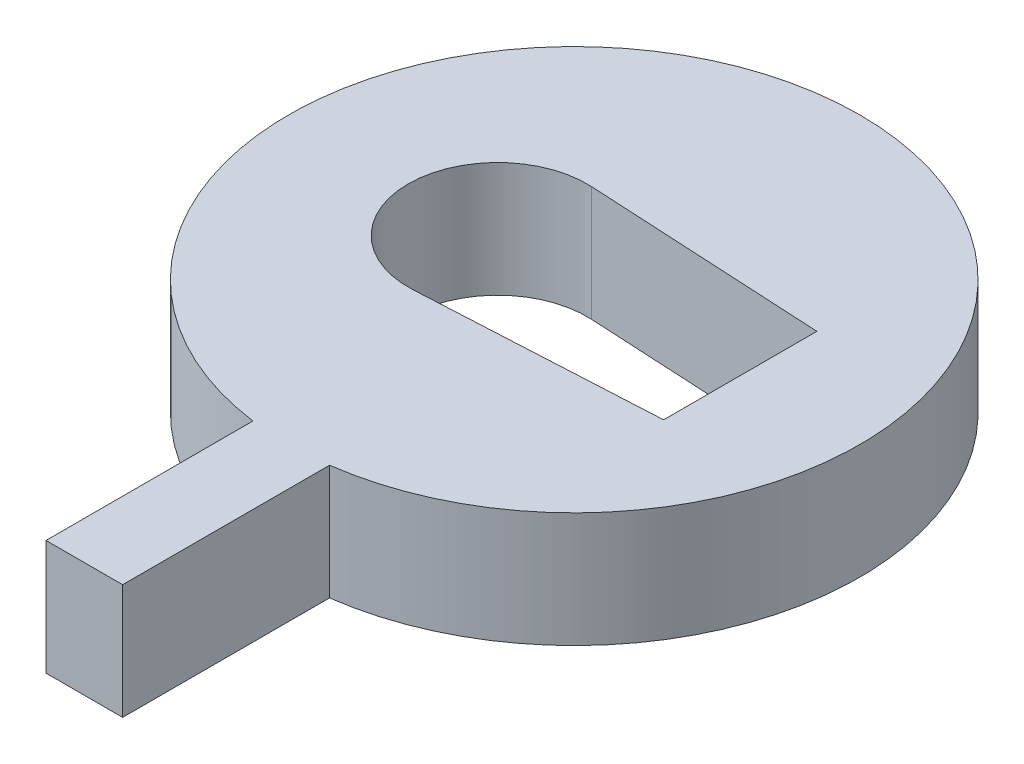
from build123d import *

# Parameters (mm, degrees)
SKETCH_1_W          = 20
SKETCH_1_H          = 10
EXTRUDE_1_DEPTH     = 4.5
CUT_EXTRUDE_1_DEPTH = 4.5
EXTRUDE_2_DEPTH     = 4.5
SKETCH_5_W          = 3
SKETCH_5_H          = 3
CUT_EXTRUDE_2_DEPTH = 4.5
SKETCH_6_W          = 3
SKETCH_6_H          = 4.5
EXTRUDE_3_DEPTH     = 11


with BuildPart() as part:
    # 草图1 → 凸台-拉伸1 (new body)
    with BuildSketch(Plane(origin=(0, 0, 0), x_dir=(1, 0, 0), z_dir=(0, 1, 0))):
        Rectangle(SKETCH_1_W, SKETCH_1_H)
    extrude(amount=EXTRUDE_1_DEPTH)

    # 草图2 → 切除-拉伸1 (cut)
    with BuildSketch(Plane(origin=(0, 4.5, 0), x_dir=(1, 0, 0), z_dir=(0, 1, 0))):
        with BuildLine():
            Line((-2.814231537, 3.495066534), (6.5, 3))
            Line((6.5, 3), (6.5, -3))
            Line((6.5, -3), (-2.814231537, -3.495066534))
            ThreePointArc((-2.814231537, -3.495066534), (-6.5, 0), (-2.814231537, 3.495066534))
        make_face()
    extrude(amount=-CUT_EXTRUDE_1_DEPTH, mode=Mode.SUBTRACT)

    # 草图3 → 凸台-拉伸2 (add)
    with BuildSketch(Plane(origin=(0, 4.5, 0), x_dir=(1, 0, 0), z_dir=(0, 1, 0))):
        with BuildLine():
            ThreePointArc((10, 5), (0, 11.180339887), (-10, 5))
            Line((-10, 5), (10, 5))
        make_face()
        with BuildLine():
            Line((-10, -5), (-10, 5))
            ThreePointArc((-10, 5), (-11.180339887, 0), (-10, -5))
        make_face()
        with BuildLine():
            Line((10, -5), (-10, -5))
            ThreePointArc((-10, -5), (0, -11.180339887), (10, -5))
        make_face()
        with BuildLine():
            ThreePointArc((11.180339887, 0), (10.881254497, 2.568715742), (10, 5))
            Line((10, 5), (10, -5))
            ThreePointArc((10, -5), (10.881254497, -2.568715742), (11.180339887, 0))
        make_face()
    extrude(amount=-EXTRUDE_2_DEPTH)

    # 草图5 → 切除-拉伸2 (cut)
    with BuildSketch(Plane(origin=(0, 4.5, 0), x_dir=(1, 0, 0), z_dir=(0, 1, 0))):
        with Locations((0, -9.680339887)):
            Rectangle(SKETCH_5_W, SKETCH_5_H)
    extrude(amount=-CUT_EXTRUDE_2_DEPTH, mode=Mode.SUBTRACT)

    # 草图6 → 凸台-拉伸3 (add)
    with BuildSketch(Plane.XY.offset(8.180339887)):
        with Locations((0, 2.25)):
            Rectangle(SKETCH_6_W, SKETCH_6_H)
    extrude(amount=EXTRUDE_3_DEPTH)


solid = part.part
